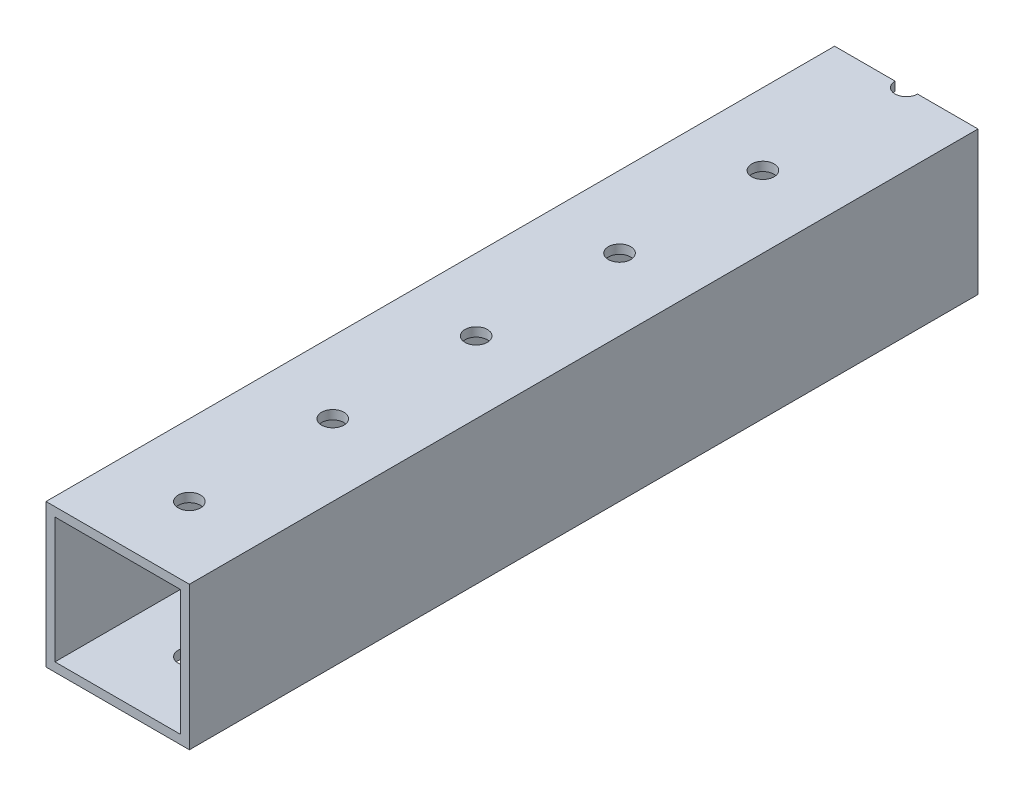
from build123d import *

# Parameters (mm, degrees)
SKETCH1_W           = 25.4
SKETCH1_H           = 25.4
SKETCH1_W_2         = 22.225
SKETCH1_H_2         = 22.225
BOSS_EXTRUDE1_DEPTH = 139.7
SKETCH2_R           = 1.984375
CUT_EXTRUDE1_DEPTH  = 26.4


with BuildPart() as part:
    # Sketch1 → Boss-Extrude1 (new body)
    with BuildSketch(Plane.XY):
        Rectangle(SKETCH1_W, SKETCH1_H)
        Rectangle(SKETCH1_W_2, SKETCH1_H_2, mode=Mode.SUBTRACT)
    extrude(amount=BOSS_EXTRUDE1_DEPTH)

    # Sketch2 → Cut-Extrude1 (cut, through all)
    with BuildSketch(Plane(origin=(0, 12.7, 0), x_dir=(1, 0, 0), z_dir=(0, 1, 0))):
        with Locations((0, -127)):
            Circle(SKETCH2_R)
        with Locations((0, -101.6)):
            Circle(SKETCH2_R)
        with Locations((0, -76.2)):
            Circle(SKETCH2_R)
        with Locations((0, -50.8)):
            Circle(SKETCH2_R)
        with Locations((0, -25.4)):
            Circle(SKETCH2_R)
        Circle(SKETCH2_R)
        with Locations((0, 25.4)):
            Circle(SKETCH2_R)
        with Locations((0, 50.8)):
            Circle(SKETCH2_R)
        with Locations((0, 76.2)):
            Circle(SKETCH2_R)
        with Locations((0, 101.6)):
            Circle(SKETCH2_R)
        with Locations((0, 127)):
            Circle(SKETCH2_R)
        with Locations((0, 152.4)):
            Circle(SKETCH2_R)
    extrude(amount=-CUT_EXTRUDE1_DEPTH, mode=Mode.SUBTRACT)


solid = part.part
